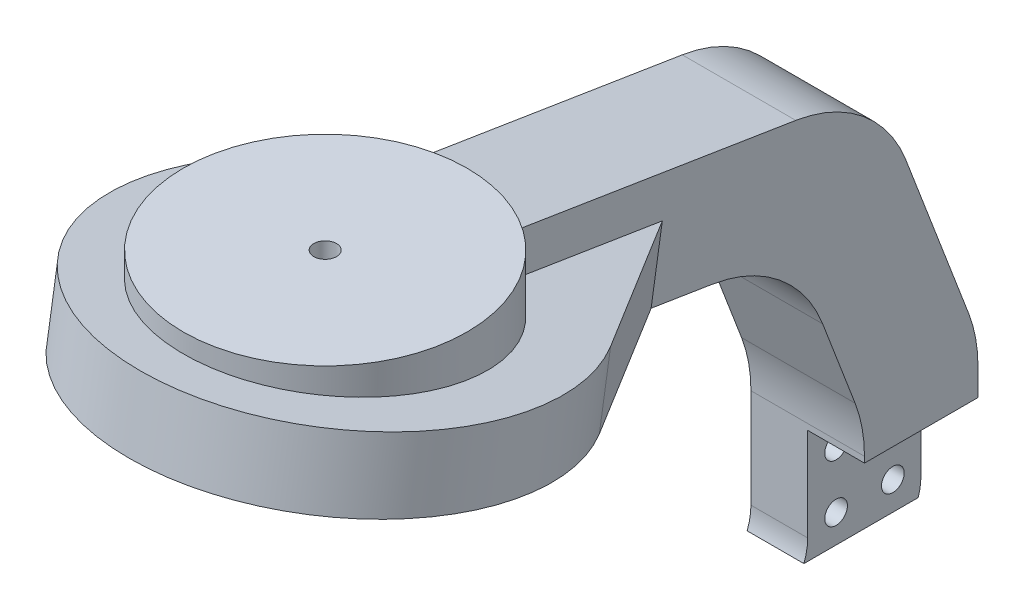
from build123d import *

# Parameters (mm, degrees)
CROQUIS1_R              = 25
CROQUIS1_R_2            = 2
SALIENTE_EXTRUIR1_DEPTH = 20
SALIENTE_EXTRUIR2_DEPTH = 10
SALIENTE_EXTRUIR3_DEPTH = 12.5
CROQUIS5_W              = 20
CROQUIS5_H              = 20
CORTAR_EXTRUIR1_DEPTH   = 10
CROQUIS6_R              = 2
CORTAR_EXTRUIR2_DEPTH   = 10
CROQUIS7_R              = 2
CORTAR_EXTRUIR3_DEPTH   = 143.653426177
CORTAR_EXTRUIR4_DEPTH   = 5
REDONDEO1_R             = 25
SALIENTE_EXTRUIR4_DEPTH = 10
CORTAR_EXTRUIR5_DEPTH   = 10


with BuildPart() as part:
    # Croquis1 → Saliente-Extruir1 (new body)
    with BuildSketch(Plane(origin=(0, 0, 0), x_dir=(1, 0, 0), z_dir=(0, 1, 0))):
        with Locations(Location((0, 0, 0), (0, 0, 270))):
            Circle(CROQUIS1_R)
        with Locations(Location((0, 0, 0), (0, 0, 270))):
            Circle(CROQUIS1_R_2, mode=Mode.SUBTRACT)
    extrude(amount=SALIENTE_EXTRUIR1_DEPTH)

    # Croquis3 → Saliente-Extruir2 (add, symmetric)
    with BuildSketch(Plane(origin=(0, 0, 0), x_dir=(0, 0, -1), z_dir=(1, 0, 0))):
        Polygon((0, 20), (25, 16), (87.155173578, 6.055172228), (105, -40.652023899), (105, -70), (85, -70), (85, -44.34250964), (72.489864787, -11.598378366), (25, -4), (0, 0), align=None)
    extrude(amount=SALIENTE_EXTRUIR2_DEPTH, both=True)

    # Croquis4 → Saliente-Extruir3 (add)
    with BuildSketch(Plane(origin=(0, 0, 0), x_dir=(1, 0, 0), z_dir=(0, -0.9874406319167053, 0.15799050110667304))):
        with BuildLine():
            Line((-10, -48.018489352), (-29.097101252, -19.451444643))
            ThreePointArc((-29.097101252, -19.451444643), (0, 35), (29.097101252, -19.451444643))
            Line((29.097101252, -19.451444643), (10, -48.018489352))
            Line((10, -48.018489352), (-10, -48.018489352))
        make_face()
    extrude(amount=-SALIENTE_EXTRUIR3_DEPTH)

    # Croquis5 → Cortar-Extruir1 (cut)
    with BuildSketch(Plane(origin=(10, 0, 0), x_dir=(0, 0, -1), z_dir=(1, 0, 0))):
        with Locations((95, -60)):
            Rectangle(CROQUIS5_W, CROQUIS5_H)
    extrude(amount=-CORTAR_EXTRUIR1_DEPTH, mode=Mode.SUBTRACT)

    # Croquis6 → Cortar-Extruir2 (cut)
    with BuildSketch(Plane(origin=(0, 0, 0), x_dir=(0, 0, -1), z_dir=(1, 0, 0))):
        with Locations((100, -55)):
            Circle(CROQUIS6_R)
        with Locations((100, -65)):
            Circle(CROQUIS6_R)
        with Locations((90, -65)):
            Circle(CROQUIS6_R)
        with Locations((90, -55)):
            Circle(CROQUIS6_R)
    extrude(amount=-CORTAR_EXTRUIR2_DEPTH, mode=Mode.SUBTRACT)

    # Croquis7 → Cortar-Extruir3 (cut, through all)
    with BuildSketch(Plane(origin=(0, 20, 0), x_dir=(1, 0, 0), z_dir=(0, 1, 0))):
        with Locations(Location((0, 0, 0), (0, 0, 180))):
            Circle(CROQUIS7_R)
    extrude(amount=-CORTAR_EXTRUIR3_DEPTH, mode=Mode.SUBTRACT)

    # Croquis8 → Cortar-Extruir4 (cut, symmetric)
    with BuildSketch(Plane.XZ):
        Polygon((5, 0), (2.5, 4.330127019), (-2.5, 4.330127019), (-5, 0), (-2.5, -4.330127019), (2.5, -4.330127019), align=None)
    extrude(amount=CORTAR_EXTRUIR4_DEPTH, both=True, mode=Mode.SUBTRACT)

    # Redondeo1
    redondeo1_edges = [part.edges().sort_by_distance(p)[0] for p in [
        (0, -11.598378366, -72.489864787),
        (0, -44.34250964, -85),
        (0, -40.652023899, -105),
        (0, 6.055172228, -87.155173578),
    ]]
    fillet(redondeo1_edges, radius=REDONDEO1_R)

    # Croquis9 → Saliente-Extruir4 (add)
    with BuildSketch(Plane.ZY.offset(10)):
        with BuildLine():
            Line((-85, -70), (-84.332978708, -70))
            ThreePointArc((-84.332978708, -70), (-84.831826004, -68.238225633), (-85, -66.414927782))
            Line((-85, -66.414927782), (-85, -70))
        make_face()
    extrude(amount=-SALIENTE_EXTRUIR4_DEPTH)

    # Croquis10 → Cortar-Extruir5 (cut)
    with BuildSketch(Plane(origin=(0, 0, 0), x_dir=(0, 0, -1), z_dir=(1, 0, 0))):
        Polygon((105, -66.754605318), (105, -70), (104.45872155, -70), (104.782079233, -68.830882246), align=None)
    extrude(amount=-CORTAR_EXTRUIR5_DEPTH, mode=Mode.SUBTRACT)


solid = part.part
